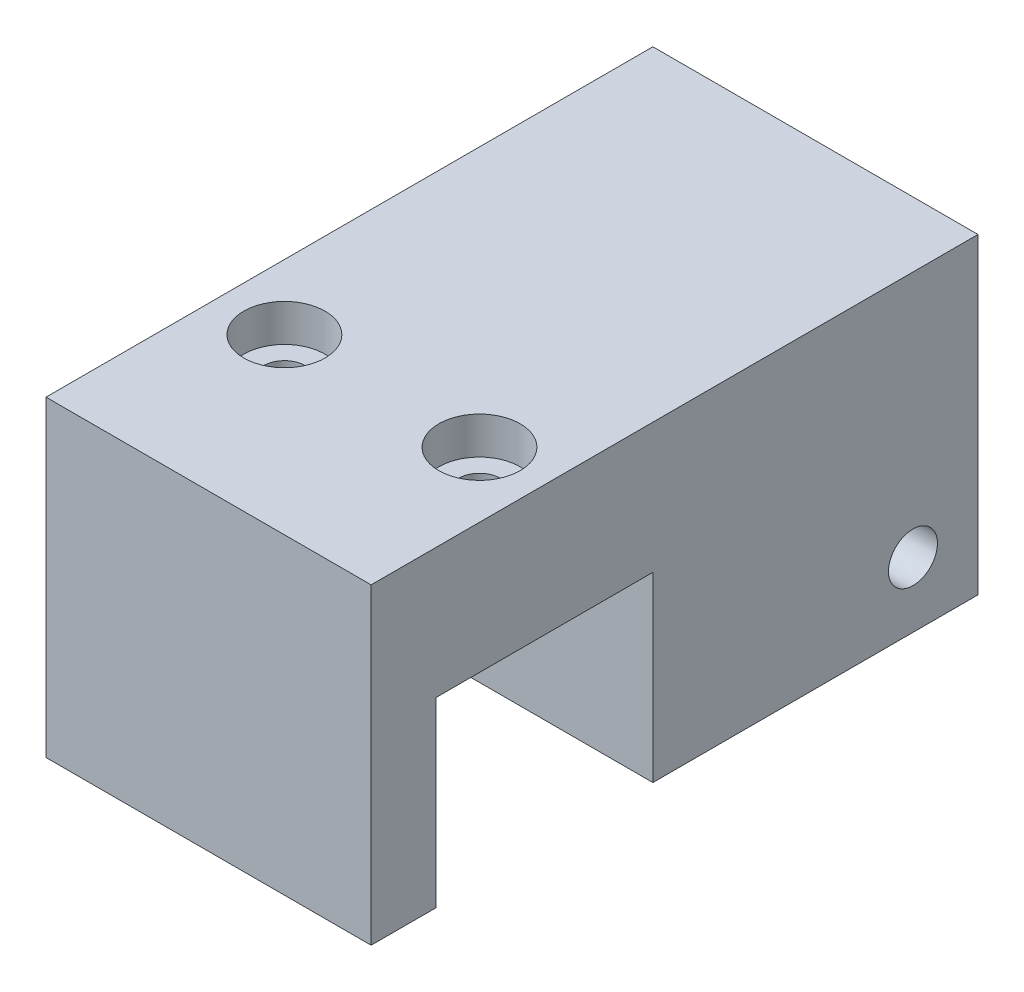
from build123d import *

# Parameters (mm, degrees)
BOSS_EXTRUDE1_DEPTH                            = 19.05
CBORE_FOR_2_SOCKET_HEAD_CAP_SCREW1_D           = 2.4384
CBORE_FOR_2_SOCKET_HEAD_CAP_SCREW1_CBORE_D     = 4.7625
CBORE_FOR_2_SOCKET_HEAD_CAP_SCREW1_CBORE_DEPTH = 2.1844
F_6_40_TAPPED_HOLE2_D                          = 2.8702


with BuildPart() as part:
    # Sketch1 → Boss-Extrude1 (new body)
    with BuildSketch(Plane(origin=(0, 0, 0), x_dir=(0, 0, -1), z_dir=(1, 0, 0))):
        Polygon((-8.89, 0), (10.16, 0), (10.16, 18.288), (-25.4, 18.288), (-25.4, 0), (-21.59, 0), (-21.59, 10.668), (-8.89, 10.668), align=None)
    extrude(amount=BOSS_EXTRUDE1_DEPTH)

    # CBORE for #2 Socket Head Cap Screw1 (through all)
    with Locations(Plane(origin=(0, 18.288, 0), x_dir=(-1, 0, 0), z_dir=(0, 1, 0))):
        with Locations((-3.81, 15.24), (-15.24, 15.24)):
            CounterBoreHole(CBORE_FOR_2_SOCKET_HEAD_CAP_SCREW1_D / 2, CBORE_FOR_2_SOCKET_HEAD_CAP_SCREW1_CBORE_D / 2, CBORE_FOR_2_SOCKET_HEAD_CAP_SCREW1_CBORE_DEPTH)

    # #6-40 Tapped Hole2 (through all)
    with Locations(Plane.ZY):
        with Locations((-6.35, 3.81)):
            Hole(F_6_40_TAPPED_HOLE2_D / 2)


solid = part.part
